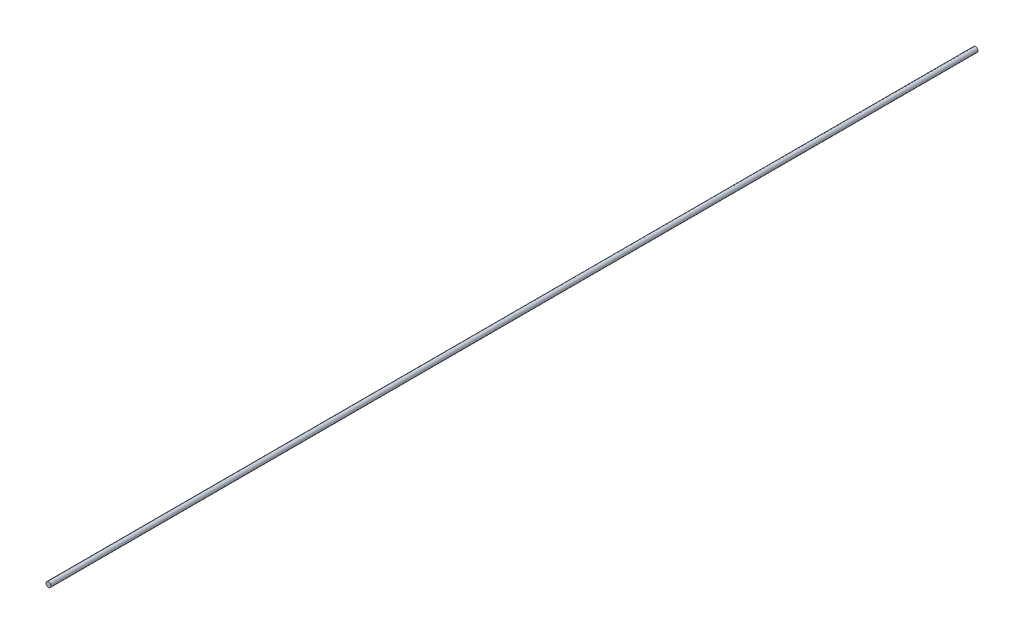
from build123d import *

# Parameters (mm, degrees)
SKETCH1_R           = 1.8161
BOSS_EXTRUDE1_DEPTH = 685.8


with BuildPart() as part:
    # Sketch1 → Boss-Extrude1 (new body)
    with BuildSketch(Plane.XY):
        Circle(SKETCH1_R)
    extrude(amount=BOSS_EXTRUDE1_DEPTH)


solid = part.part
